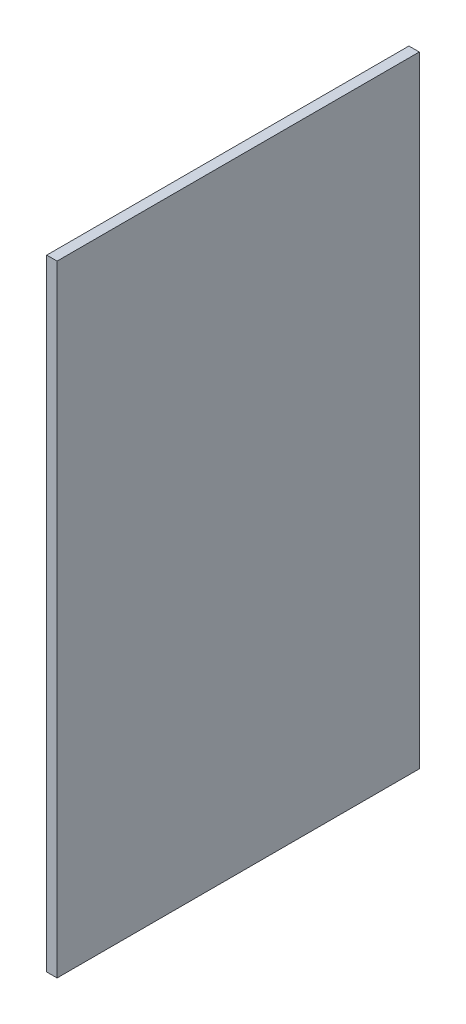
from build123d import *

# Parameters (mm, degrees)
SKETCH1_W           = 2
SKETCH1_H           = 70
BOSS_EXTRUDE1_DEPTH = 120


with BuildPart() as part:
    # Sketch1 → Boss-Extrude1 (new body)
    with BuildSketch(Plane(origin=(0, 0, 0), x_dir=(1, 0, 0), z_dir=(0, 1, 0))):
        Rectangle(SKETCH1_W, SKETCH1_H)
    extrude(amount=BOSS_EXTRUDE1_DEPTH)


solid = part.part
